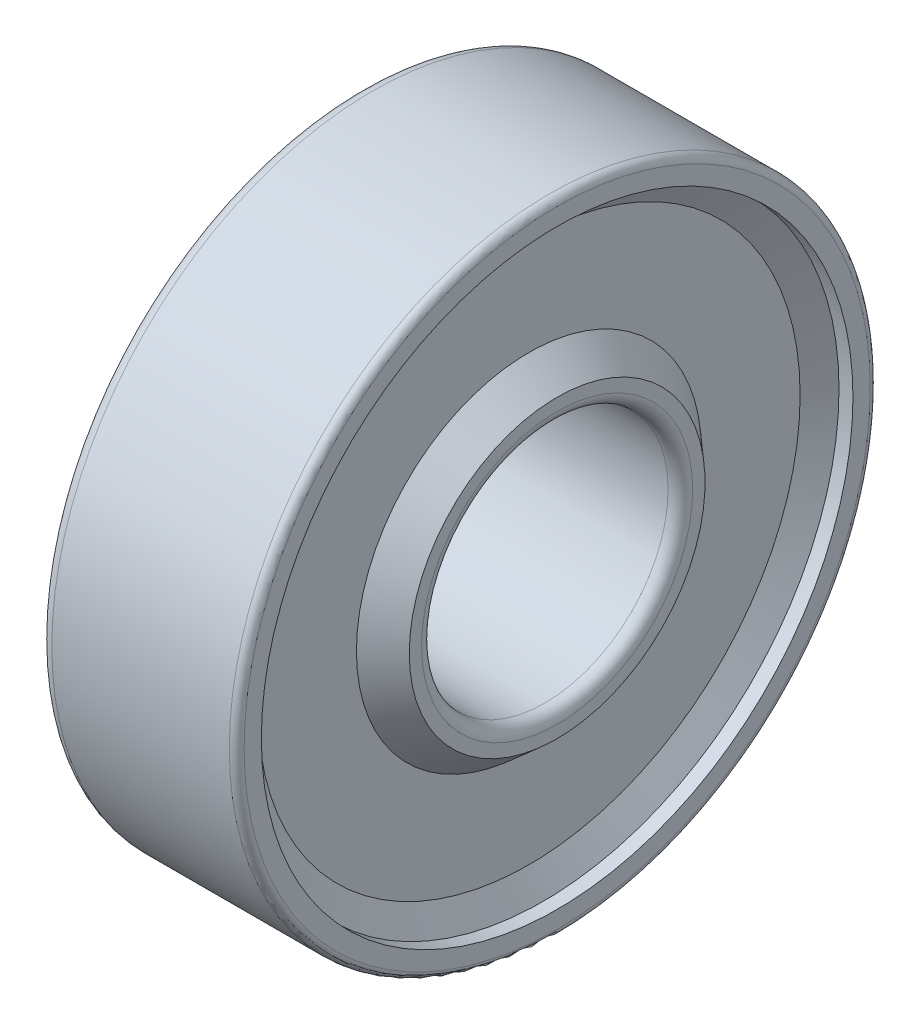
from build123d import *


with BuildPart() as part:
    # Эскиз1 → Повернуть1 (revolve)
    with BuildSketch(Plane.XY):
        with BuildLine():
            Line((-3.5, 13), (3.7, 13))
            ThreePointArc((3.7, 13), (3.912132034, 12.912132034), (4, 12.7))
            Line((4, 12.7), (4, 12))
            Line((4, 12), (3.434493126, 12))
            Line((3.434493126, 12), (2.857142857, 11))
            Line((2.857142857, 11), (2.857142857, 7))
            Line((2.857142857, 7), (4, 6))
            Line((4, 6), (4, 5.5))
            ThreePointArc((4, 5.5), (3.853553391, 5.146446609), (3.5, 5))
            Line((3.5, 5), (-3.5, 5))
            ThreePointArc((-3.5, 5), (-3.853553391, 5.146446609), (-4, 5.5))
            Line((-4, 5.5), (-4, 6))
            Line((-4, 6), (-2.857142857, 7))
            Line((-2.857142857, 7), (-2.857142857, 11))
            Line((-2.857142857, 11), (-4, 12))
            Line((-4, 12), (-4, 12.5))
            ThreePointArc((-4, 12.5), (-3.853553391, 12.853553391), (-3.5, 13))
        make_face()
    revolve(axis=Axis((-1000, 0, 0), (1, 0, 0)))


solid = part.part
